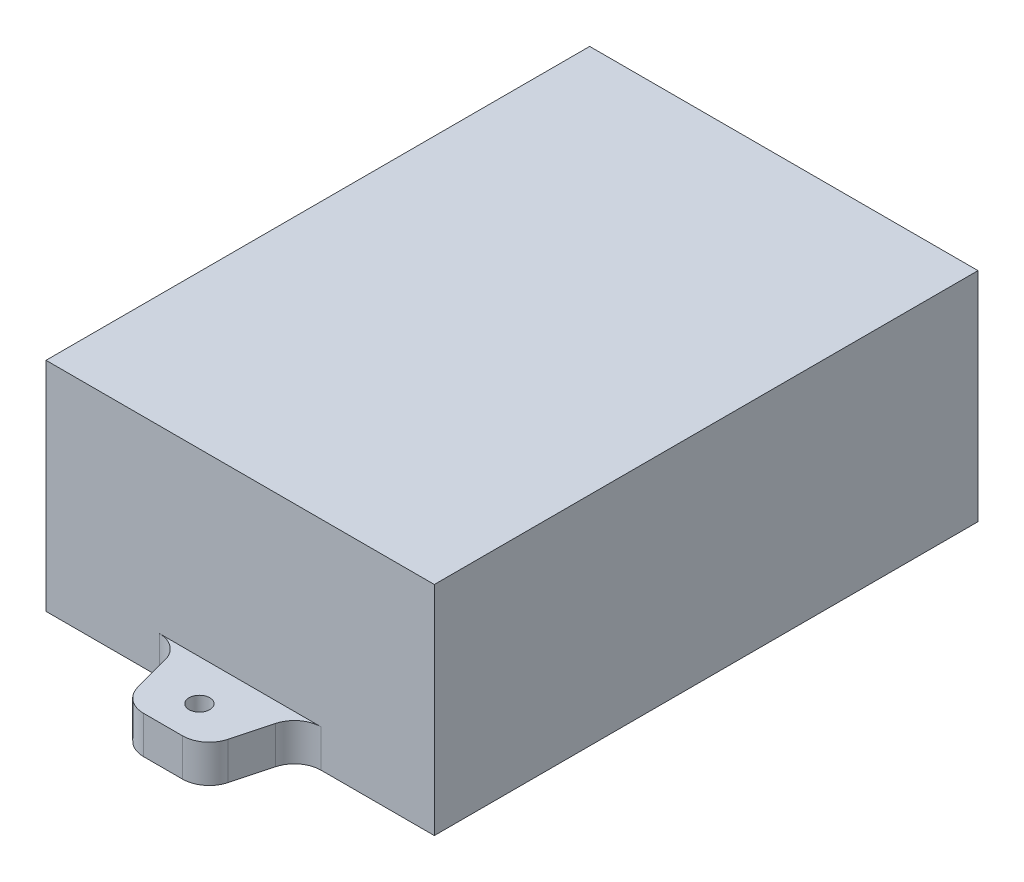
from build123d import *

# Parameters (mm, degrees)
SKETCH1_W           = 60
SKETCH1_H           = 84
BOSS_EXTRUDE1_DEPTH = 33.6
SKETCH2_R           = 1.6
BOSS_EXTRUDE2_DEPTH = 5.8


with BuildPart() as part:
    # Sketch1 → Boss-Extrude1 (new body)
    with BuildSketch(Plane(origin=(0, 0, 0), x_dir=(1, 0, 0), z_dir=(0, 1, 0))):
        Rectangle(SKETCH1_W, SKETCH1_H)
    extrude(amount=BOSS_EXTRUDE1_DEPTH)

    # Sketch2 → Boss-Extrude2 (add)
    with BuildSketch(Plane(origin=(0, 0, 0), x_dir=(1, 0, 0), z_dir=(0, 1, 0))):
        with BuildLine():
            Line((-12.5, 42), (12.5, 42))
            ThreePointArc((12.5, 42), (9.996413035, 42.849853258), (8.527541838, 45.048174357))
            Line((8.527541838, 45.048174357), (6.972458162, 50.851825643))
            ThreePointArc((6.972458162, 50.851825643), (5.503586965, 53.050146742), (3, 53.9))
            Line((3, 53.9), (-3, 53.9))
            ThreePointArc((-3, 53.9), (-5.503586965, 53.050146742), (-6.972458162, 50.851825643))
            Line((-6.972458162, 50.851825643), (-8.527541838, 45.048174357))
            ThreePointArc((-8.527541838, 45.048174357), (-9.996413035, 42.849853258), (-12.5, 42))
        make_face()
        with Locations((0, 48.3)):
            Circle(SKETCH2_R, mode=Mode.SUBTRACT)
        with BuildLine():
            Line((6.972458162, -50.851825643), (8.527541838, -45.048174357))
            ThreePointArc((8.527541838, -45.048174357), (9.996413035, -42.849853258), (12.5, -42))
            Line((12.5, -42), (-12.5, -42))
            ThreePointArc((-12.5, -42), (-9.996413035, -42.849853258), (-8.527541838, -45.048174357))
            Line((-8.527541838, -45.048174357), (-6.972458162, -50.851825643))
            ThreePointArc((-6.972458162, -50.851825643), (-5.503586965, -53.050146742), (-3, -53.9))
            Line((-3, -53.9), (3, -53.9))
            ThreePointArc((3, -53.9), (5.503586965, -53.050146742), (6.972458162, -50.851825643))
        make_face()
        with Locations((0, -48.3)):
            Circle(SKETCH2_R, mode=Mode.SUBTRACT)
    extrude(amount=BOSS_EXTRUDE2_DEPTH)


solid = part.part
